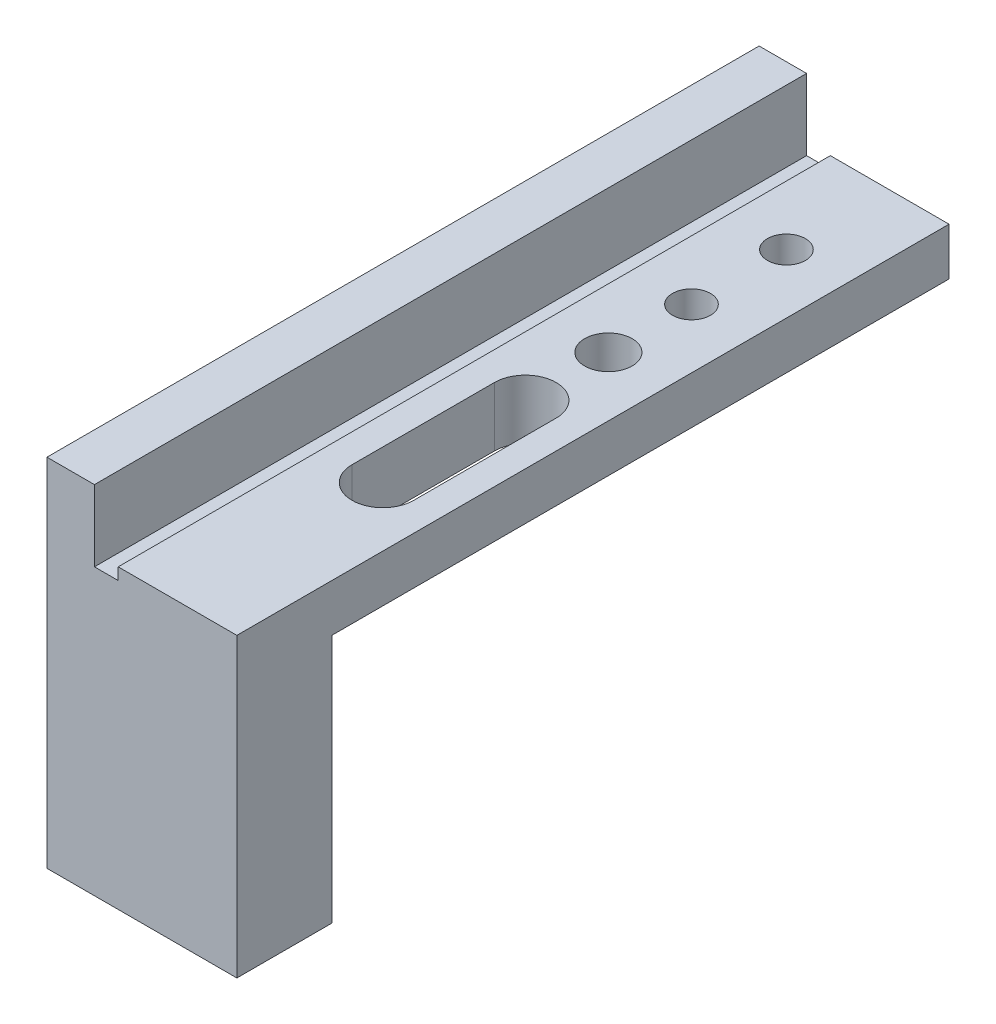
from build123d import *

# Parameters (mm, degrees)
BOSS_EXTRUDE1_DEPTH   = 30
SKETCH3_R             = 1
CUT_EXTRUDE1_DEPTH    = 10
M2_TAPPED_HOLE1_D     = 1.6
M2_TAPPED_HOLE1_DEPTH = 5.2
M2_TAPPED_HOLE1_TIP   = 0.480688495
SKETCH2_W             = 8
SKETCH2_H             = 4
BOSS_EXTRUDE2_DEPTH   = 10
CHAMFER1_SIZE         = 0.5


with BuildPart() as part:
    # Sketch1 → Boss-Extrude1 (new body)
    with BuildSketch(Plane.XY):
        Polygon((-5.152542373, 3), (-3.152542373, 3), (-3.152542373, 0), (-2.152542373, 0), (-2.152542373, 0.5), (2.847457627, 0.5), (2.847457627, -2), (-5.152542373, -2), align=None)
    extrude(amount=BOSS_EXTRUDE1_DEPTH)

    # Sketch3 → Cut-Extrude1 (cut)
    with BuildSketch(Plane(origin=(0, 0.5, 0), x_dir=(1, 0, 0), z_dir=(0, 1, 0))):
        with Locations((0.347457627, -11.85)):
            Circle(SKETCH3_R)
        with BuildLine():
            Line((-0.952542373, -21.35), (-0.952542373, -15.35))
            ThreePointArc((-0.952542373, -15.35), (0.347457627, -14.05), (1.647457627, -15.35))
            Line((1.647457627, -15.35), (1.647457627, -21.35))
            ThreePointArc((1.647457627, -21.35), (0.347457627, -22.65), (-0.952542373, -21.35))
        make_face()
    extrude(amount=-CUT_EXTRUDE1_DEPTH, mode=Mode.SUBTRACT)

    # M2 Tapped Hole1
    with Locations(Plane(origin=(0, 0.5, 0), x_dir=(1, 0, 0), z_dir=(0, 1, 0))):
        with Locations((0.347457627, -4.35), (0.347457627, -8.35)):
            Hole(M2_TAPPED_HOLE1_D / 2, depth=M2_TAPPED_HOLE1_DEPTH)
            with Locations((0, 0, -(M2_TAPPED_HOLE1_DEPTH + M2_TAPPED_HOLE1_TIP / 2))):  # 118° drill point
                Cone(0, M2_TAPPED_HOLE1_D / 2, M2_TAPPED_HOLE1_TIP, mode=Mode.SUBTRACT)

    # Sketch2 → Boss-Extrude2 (add)
    with BuildSketch(Plane.XZ.offset(2)):
        with Locations((-1.152542373, 28)):
            Rectangle(SKETCH2_W, SKETCH2_H)
    extrude(amount=BOSS_EXTRUDE2_DEPTH)

    # Chamfer1
    chamfer1_edges = [part.edges().sort_by_distance(p)[0] for p in [
        (2.847457627, -2, 13),
        (-5.152542373, -2, 13),
    ]]
    chamfer(chamfer1_edges, length=CHAMFER1_SIZE)


solid = part.part
